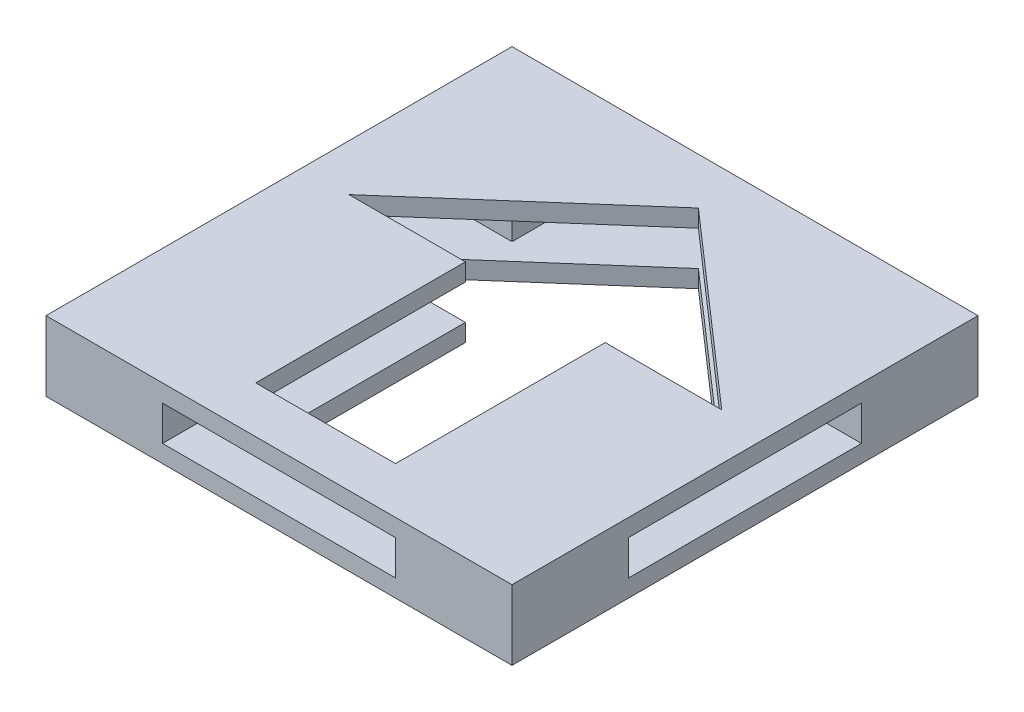
from build123d import *

# Parameters (mm, degrees)
SKETCH1_W           = 20
SKETCH1_H           = 20
BOSS_EXTRUDE1_DEPTH = 3
SKETCH2_W           = 10
SKETCH2_H           = 1.5
CUT_EXTRUDE1_DEPTH  = 21
SKETCH3_W           = 10
SKETCH3_H           = 1.5
CUT_EXTRUDE2_DEPTH  = 21


with BuildPart() as part:
    # Sketch1 → Boss-Extrude1 (new body)
    with BuildSketch(Plane(origin=(0, 0, 0), x_dir=(1, 0, 0), z_dir=(0, 1, 0))):
        Rectangle(SKETCH1_W, SKETCH1_H)
        Polygon((-8, 1), (-3, 1), (-3, -8), (3, -8), (3, 1), (8, 1), (0, 8), align=None, mode=Mode.SUBTRACT)
    extrude(amount=BOSS_EXTRUDE1_DEPTH)

    # Sketch2 → Cut-Extrude1 (cut, through all)
    with BuildSketch(Plane.XY.offset(10)):
        with Locations((0, 1.5)):
            Rectangle(SKETCH2_W, SKETCH2_H)
    extrude(amount=-CUT_EXTRUDE1_DEPTH, mode=Mode.SUBTRACT)

    # Sketch3 → Cut-Extrude2 (cut, through all)
    with BuildSketch(Plane(origin=(10, 0, 0), x_dir=(0, 0, -1), z_dir=(1, 0, 0))):
        with Locations((0, 1.5)):
            Rectangle(SKETCH3_W, SKETCH3_H)
    extrude(amount=-CUT_EXTRUDE2_DEPTH, mode=Mode.SUBTRACT)


solid = part.part
